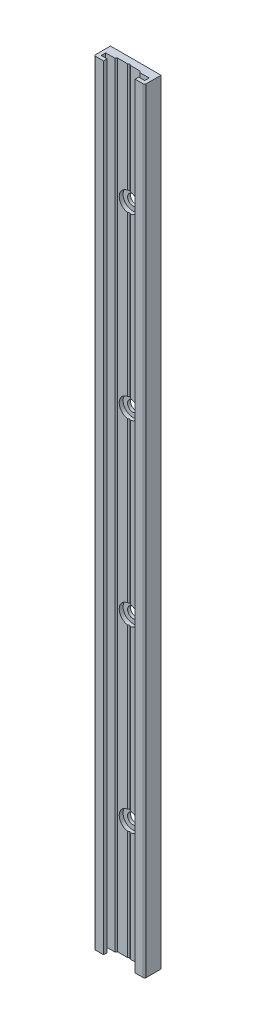
from build123d import *

# Parameters (mm, degrees)
SKETCH1_W           = 17
SKETCH1_H           = 260
BOSS_EXTRUDE1_DEPTH = 5.5
CUT_EXTRUDE1_DEPTH  = 261
DRAFT1_ANGLE        = 45
DRAFT2_ANGLE        = 45
DRAFT3_ANGLE        = 60.000000395
FILLET1_R           = 0.5


with BuildPart() as part:
    # Sketch1 → Boss-Extrude1 (new body)
    with BuildSketch(Plane.XY.offset(5.5)):
        with Locations((0, 130)):
            Rectangle(SKETCH1_W, SKETCH1_H)
    extrude(amount=-BOSS_EXTRUDE1_DEPTH)

    # Sketch2 → Cut-Extrude1 (cut, through all)
    with BuildSketch(Plane.XZ):
        Polygon((5.3, 5.5), (-5.3, 5.5), (-5.3, 4.3), (-7.3, 4.3), (-7.3, 2.8), (-4.25, 2.8), (-4.25, 2.3), (-0.5, 2.3), (0.499999996, 1.722649733), (0.499999996, 2.3), (3.75, 2.3), (3.75, 2.8), (7.3, 2.8), (7.3, 4.3), (5.3, 4.3), align=None)
    extrude(amount=-CUT_EXTRUDE1_DEPTH, mode=Mode.SUBTRACT)

    # Draft1
    draft1_faces = [part.faces().sort_by_distance(p)[0] for p in [
        (-4.25, 130, 2.55),
    ]]
    draft(draft1_faces, Plane(origin=(-7.3, 260, 2.8), x_dir=(1, 0, 0), z_dir=(0, 0, 1)), DRAFT1_ANGLE)

    # Draft2
    draft2_faces = [part.faces().sort_by_distance(p)[0] for p in [
        (3.75, 130, 2.55),
    ]]
    draft(draft2_faces, Plane(origin=(0.499999996, 260, 2.3), x_dir=(1, 0, 0), z_dir=(0, 0, 1)), DRAFT2_ANGLE)

    # Draft3
    draft3_faces = [part.faces().sort_by_distance(p)[0] for p in [
        (0.499999996, 130, 2.011324867),
    ]]
    draft(draft3_faces, Plane(origin=(0.499999996, 260, 2.3), x_dir=(1, 0, 0), z_dir=(0, 0, 1)), DRAFT3_ANGLE)

    # Sketch3 → Cut-Revolve1 (revolve, cut)
    with BuildSketch(Plane(origin=(0, 160, 0), x_dir=(1, 0, 0), z_dir=(0, 1, 0))):
        Polygon((1.75, 0), (0, 0), (0, -2.3), (3.25, -2.3), (3.25, -1), (1.75, -1), align=None)
    revolve(axis=Axis((0, 160, 0), (0, 0, 1)), mode=Mode.SUBTRACT)

    # Sketch4 → Cut-Revolve2 (revolve, cut)
    with BuildSketch(Plane(origin=(0, 100, 0), x_dir=(1, 0, 0), z_dir=(0, 1, 0))):
        Polygon((1.75, 0), (0, 0), (0, -2.3), (3.25, -2.3), (3.25, -1), (1.75, -1), align=None)
    revolve(axis=Axis((0, 100, 0), (0, 0, 1)), mode=Mode.SUBTRACT)

    # Sketch5 → Cut-Revolve3 (revolve, cut)
    with BuildSketch(Plane(origin=(0, 40, 0), x_dir=(1, 0, 0), z_dir=(0, 1, 0))):
        Polygon((1.75, 0), (0, 0), (0, -2.3), (3.25, -2.3), (3.25, -1), (1.75, -1), align=None)
    revolve(axis=Axis((0, 40, 0), (0, 0, 1)), mode=Mode.SUBTRACT)

    # Sketch6 → Cut-Revolve4 (revolve, cut)
    with BuildSketch(Plane(origin=(0, 220, 0), x_dir=(1, 0, 0), z_dir=(0, 1, 0))):
        Polygon((1.75, 0), (0, 0), (0, -2.3), (3.25, -2.3), (3.25, -1), (1.75, -1), align=None)
    revolve(axis=Axis((0, 220, 0), (0, 0, 1)), mode=Mode.SUBTRACT)

    # Fillet1
    fillet1_edges = [part.edges().sort_by_distance(p)[0] for p in [
        (8.5, 130, 5.5),
        (-8.5, 130, 5.5),
    ]]
    fillet(fillet1_edges, radius=FILLET1_R)


solid = part.part
